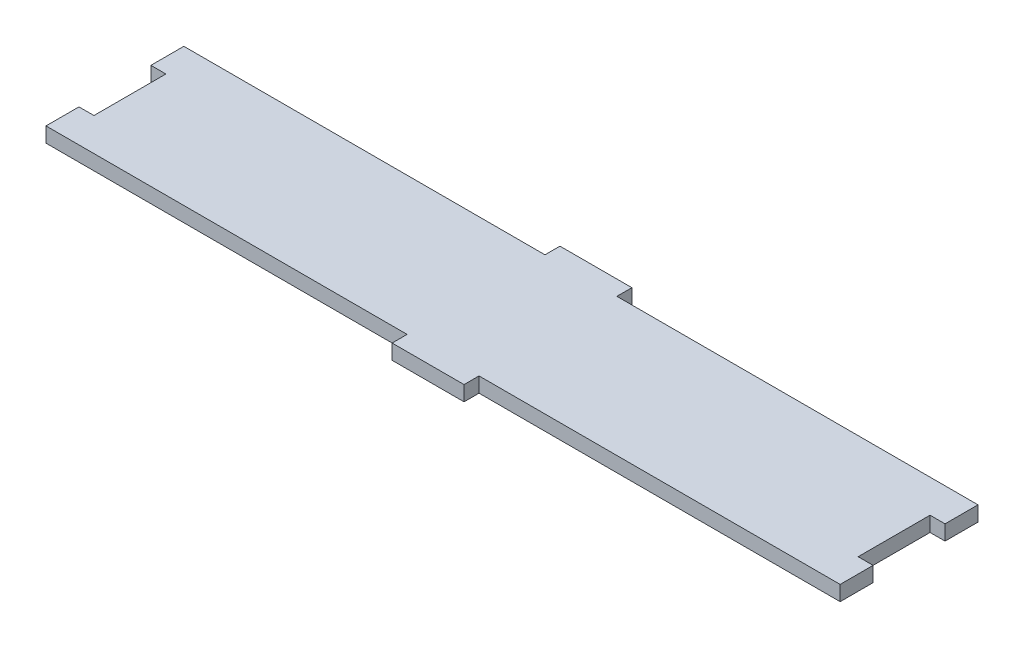
from build123d import *

# Parameters (mm, degrees)
BOSS_EXTRUDE1_DEPTH = 6.35
SKETCH2_W           = 6.35
SKETCH2_H           = 30.48
CUT_EXTRUDE1_DEPTH  = 7.35


with BuildPart() as part:
    # Sketch1 → Boss-Extrude1 (new body)
    with BuildSketch(Plane(origin=(0, 0, 0), x_dir=(1, 0, 0), z_dir=(0, 1, 0))):
        Polygon((-183.515, 0), (-336.55, 0), (-336.55, -58.42), (-183.515, -58.42), (-183.515, -64.77), (-153.035, -64.77), (-153.035, -58.42), (0, -58.42), (0, 0), (-153.035, 0), (-153.035, 6.35), (-183.515, 6.35), align=None)
    extrude(amount=BOSS_EXTRUDE1_DEPTH)

    # Sketch2 → Cut-Extrude1 (cut, through all)
    with BuildSketch(Plane(origin=(0, 6.35, 0), x_dir=(1, 0, 0), z_dir=(0, 1, 0))):
        with Locations((-333.375, -29.21)):
            Rectangle(SKETCH2_W, SKETCH2_H)
        with Locations((-3.175, -29.21)):
            Rectangle(SKETCH2_W, SKETCH2_H)
    extrude(amount=-CUT_EXTRUDE1_DEPTH, mode=Mode.SUBTRACT)


solid = part.part
